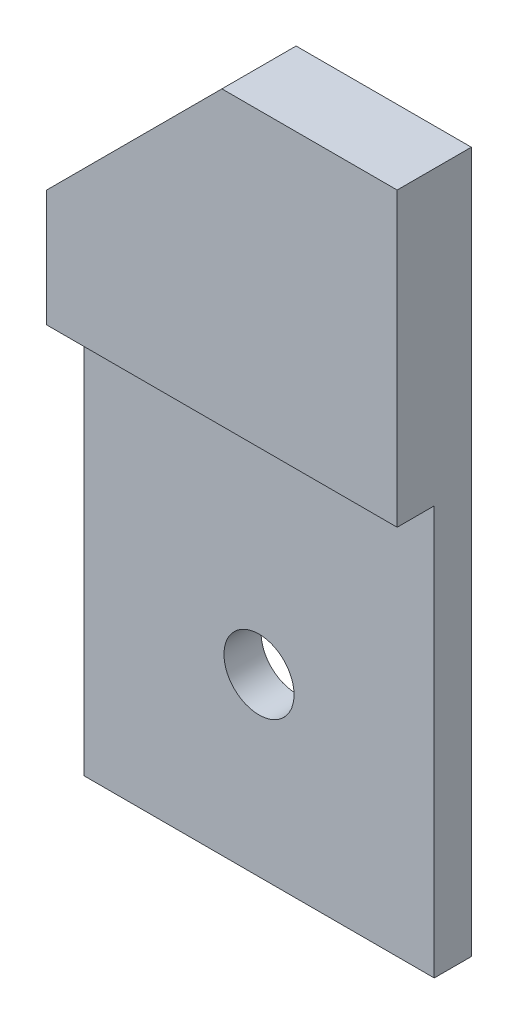
from build123d import *

# Parameters (mm, degrees)
SKETCH1_R           = 3
BOSS_EXTRUDE1_DEPTH = 3.175
BOSS_EXTRUDE2_DEPTH = 3.175


with BuildPart() as part:
    # Sketch1 → Boss-Extrude1 (new body)
    with BuildSketch(Plane.XY):
        Polygon((15, 60), (0, 45), (0, 0), (30, 0), (30, 60), align=None)
        with Locations((15, 15)):
            Circle(SKETCH1_R, mode=Mode.SUBTRACT)
    extrude(amount=BOSS_EXTRUDE1_DEPTH)

    # Sketch2 → Boss-Extrude2 (add)
    with BuildSketch(Plane.XY.offset(3.175)):
        Polygon((15, 60), (0, 45), (0, 35), (30, 35), (30, 45), (30, 60), align=None)
    extrude(amount=BOSS_EXTRUDE2_DEPTH)


solid = part.part
